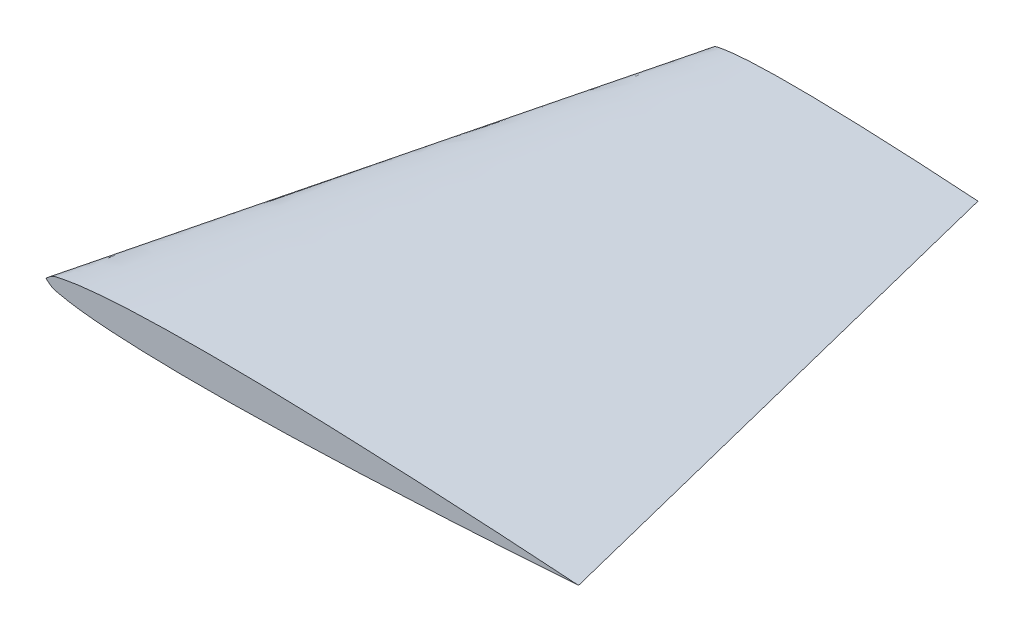
from build123d import *


with BuildPart() as part:
    # Sketch3 → Loft1 section 0
    with BuildSketch(Plane.XY):
        with BuildLine():
            add(Edge.make_bspline(
                [(25.4, 0.016002), (24.976689347, 0.045128319), (24.130173893, 0.103373674), (22.436984743, 0.211690076), (20.320476425, 0.336098703), (17.780424984, 0.468140519), (15.240441761, 0.583179797), (12.70043257, 0.676800495), (10.160373442, 0.743565548), (8.043368113, 0.766883897), (6.349891999, 0.757656949), (5.0796323, 0.732587272), (3.809233087, 0.684277408), (2.750253633, 0.617129059), (1.904339013, 0.535860237), (1.265544857, 0.459236431), (0.74159607, 0.353706876), (0.282281055, 0.260361913), (0.09976425, 0.09201755), (0, 0)],
                knots=[0, 0, 0, 0, 0.049849116, 0.099685766, 0.199326096, 0.298929012, 0.398498198, 0.498032959, 0.597533819, 0.697007218, 0.746742376, 0.796486986, 0.846259445, 0.896103226, 0.921085634, 0.946159456, 0.971462223, 0.984401163, 1, 1, 1, 1], degree=3))
            add(Edge.make_bspline(
                [(25.4, 0.016002), (24.976726383, -0.013657667), (24.13028499, -0.072969585), (22.437233662, -0.183419318), (20.320883779, -0.310494646), (17.781000726, -0.445736821), (15.24116447, -0.563976385), (12.701275256, -0.660797419), (10.161302269, -0.730762892), (8.044328001, -0.756748648), (6.350841605, -0.749655487), (5.080551327, -0.726186357), (3.810092253, -0.679477233), (2.751029032, -0.613663251), (1.905012685, -0.533460346), (1.26612249, -0.457641481), (0.742041152, -0.352772185), (0.282608887, -0.260006032), (0.099880113, -0.091891774), (0, 0)],
                knots=[0, 0, 0, 0, 0.049849116, 0.099685766, 0.199326096, 0.298929012, 0.398498198, 0.498032959, 0.597533819, 0.697007218, 0.746742376, 0.796486986, 0.846259445, 0.896103226, 0.921085634, 0.946159456, 0.971462223, 0.984401163, 1, 1, 1, 1], degree=3))
        make_face()
    # Sketch4 → Loft1 section 1
    with BuildSketch(Plane.XY.offset(-25.4)):
        with BuildLine():
            add(Edge.make_bspline(
                [(19.05, 0.0120015), (18.838363191, -0.002828334), (18.415142495, -0.032484292), (17.145609377, -0.115304932), (15.664109851, -0.19914719), (13.970582235, -0.277987693), (12.700637628, -0.32639821), (11.430651135, -0.361380946), (10.372164001, -0.374373824), (9.525420803, -0.370827243), (8.890275664, -0.359092678), (8.255046126, -0.335738117), (7.725514516, -0.302831125), (7.302506343, -0.262729673), (6.983061245, -0.224820241), (6.721020576, -0.172385592), (6.491304443, -0.126002516), (6.399940057, -0.041945387), (6.35, 0.0040005)],
                knots=[0, 0, 0, 0, 0.049849116, 0.099685766, 0.298929012, 0.398498198, 0.498032959, 0.597533819, 0.697007218, 0.746742376, 0.796486986, 0.846259445, 0.896103226, 0.921085634, 0.946159456, 0.971462223, 0.984401163, 1, 1, 1, 1], degree=3))
            add(Edge.make_bspline(
                [(19.05, 0.0120015), (18.838344674, 0.026564659), (18.415086947, 0.055687337), (17.145450483, 0.1369083), (15.663846491, 0.218883802), (13.970220881, 0.295590399), (12.700216285, 0.342400747), (11.430186721, 0.375783274), (10.371684056, 0.387442448), (9.524945999, 0.382828975), (8.88981615, 0.370294136), (8.254616544, 0.346139204), (7.725126817, 0.31256503), (7.302169507, 0.271930619), (6.982772428, 0.233618716), (6.720798035, 0.180853938), (6.491140528, 0.134181457), (6.399882125, 0.050009275), (6.35, 0.0040005)],
                knots=[0, 0, 0, 0, 0.049849116, 0.099685766, 0.298929012, 0.398498198, 0.498032959, 0.597533819, 0.697007218, 0.746742376, 0.796486986, 0.846259445, 0.896103226, 0.921085634, 0.946159456, 0.971462223, 0.984401163, 1, 1, 1, 1], degree=3))
        make_face()
    loft()


solid = part.part
